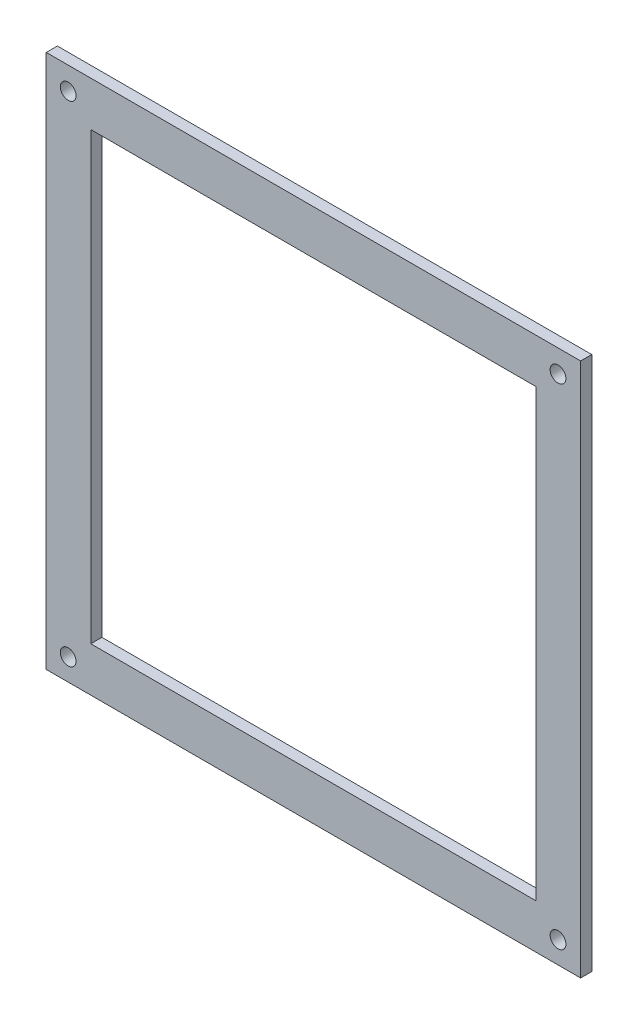
from build123d import *

# Parameters (mm, degrees)
SKETCH1_W             = 152.4
SKETCH1_H             = 152.4
SKETCH1_W_2           = 127
SKETCH1_H_2           = 127
BOSS_EXTRUDE1_DEPTH   = 3.175
F_8_CLEARANCE_HOLE2_D = 4.4958
LPATTERN1_COUNT       = 2
LPATTERN1_PITCH       = 139.7
LPATTERN1_COUNT_DIR2  = 2
LPATTERN1_PITCH_DIR2  = 139.7


with BuildPart() as part:
    # Sketch1 → Boss-Extrude1 (new body)
    with BuildSketch(Plane.XY):
        with Locations((38.331291391, -35.471688742)):
            Rectangle(SKETCH1_W, SKETCH1_H)
        with Locations((38.331291391, -35.471688742)):
            Rectangle(SKETCH1_W_2, SKETCH1_H_2, mode=Mode.SUBTRACT)
    extrude(amount=BOSS_EXTRUDE1_DEPTH)

    # #8 Clearance Hole2 (through all)
    with Locations(Plane.XY.offset(3.175)):
        with Locations((-31.616116629, 34.273559139)):
            f_8_clearance_hole2 = Hole(F_8_CLEARANCE_HOLE2_D / 2)

    # LPattern1: 8 Clearance Hole2 2 × 2
    with Locations(*[(i * LPATTERN1_PITCH, -j * LPATTERN1_PITCH_DIR2, 0) for i in range(LPATTERN1_COUNT) for j in range(LPATTERN1_COUNT_DIR2) if (i, j) != (0, 0)]):
        add(f_8_clearance_hole2, mode=Mode.SUBTRACT)


solid = part.part
